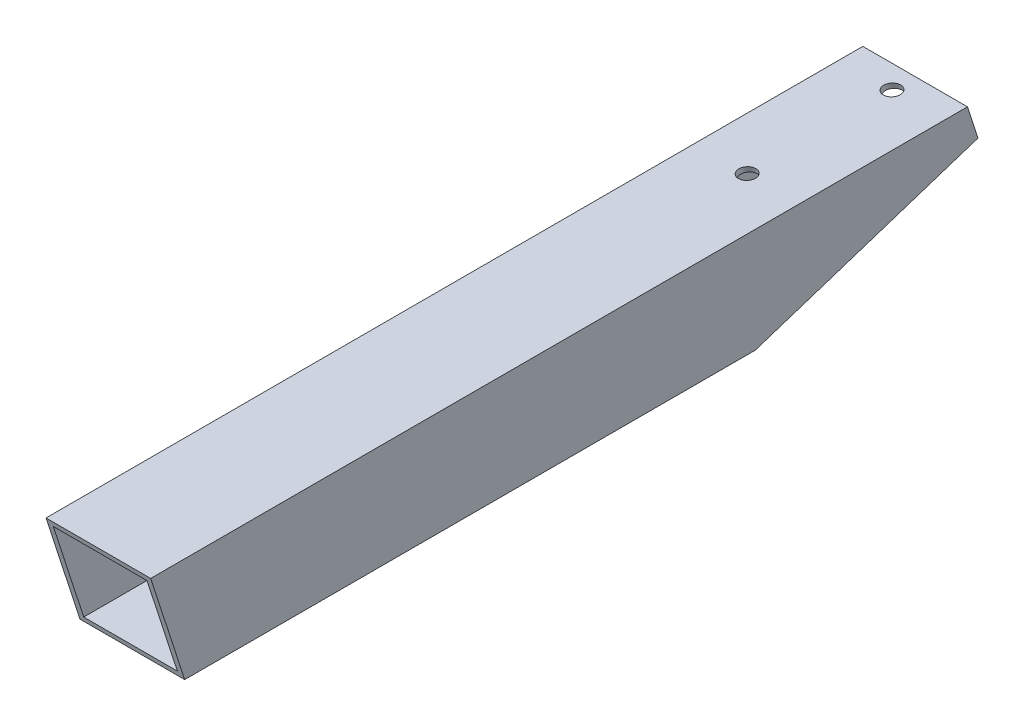
from build123d import *

# Parameters (mm, degrees)
ESBO_O1_W                = 19
ESBO_O1_H                = 19
RESSALTO_EXTRUS_O1_DEPTH = 260
CASCA2_T                 = -1
CORTE_EXTRUS_O1_DEPTH    = 20
CORTE_EXTRUS_O3_DEPTH    = 20
ESBO_O5_R                = 1.5
CORTE_EXTRUS_O4_DEPTH    = 52.987151397
ESBO_O7_W                = 19
ESBO_O7_H                = 19
CORTE_EXTRUS_O6_DEPTH    = 52.987151397


with BuildPart() as part:
    # Esboço1 → Ressalto-extrusão1 (new body)
    with BuildSketch(Plane.XY):
        Rectangle(ESBO_O1_W, ESBO_O1_H)
    extrude(amount=RESSALTO_EXTRUS_O1_DEPTH)

    # Casca2
    casca2_openings = [part.faces().sort_by_distance(p)[0] for p in [
        (0, 0, 260),
        (0, 0, 0),
    ]]
    offset(amount=CASCA2_T, openings=casca2_openings, kind=Kind.INTERSECTION)

    # Esboço2 → Corte-extrusão1 (cut, through all)
    with BuildSketch(Plane(origin=(9.5, 0, 0), x_dir=(0, 0, -1), z_dir=(1, 0, 0))):
        Polygon((0, 9.5), (-58.475987206, -9.5), (0, -9.5), align=None)
    extrude(amount=-CORTE_EXTRUS_O1_DEPTH, mode=Mode.SUBTRACT)

    # Esboço4 → Corte-extrusão3 (cut, through all)
    with BuildSketch(Plane(origin=(9.5, 0, 0), x_dir=(0, 0, -1), z_dir=(1, 0, 0))):
        Polygon((-168.550335734, 10.473717073), (-161.289503816, -11.872825786), (-264.812755879, -45.509569399), (-289.05777752, 22.149749677), (-184.516070462, 59.611196004), align=None)
    extrude(amount=-CORTE_EXTRUS_O3_DEPTH, mode=Mode.SUBTRACT)

    # Esboço5 → Corte-extrusão4 (cut, through all)
    with BuildSketch(Plane(origin=(0, 9.5, 0), x_dir=(1, 0, 0), z_dir=(0, 0.951056516, 0.309016994))):
        with Locations((0, -23)):
            Circle(ESBO_O5_R)
        with Locations((0, -48)):
            Circle(ESBO_O5_R)
    extrude(amount=CORTE_EXTRUS_O4_DEPTH, mode=Mode.SUBTRACT)

    # Esboço7 → Corte-extrusão6 (cut, through all)
    with BuildSketch(Plane(origin=(0, 8.592830723, 2.791979948), x_dir=(1, 0, 0), z_dir=(0, -0.951056516, -0.309016994))):
        with Locations((0, 6.564338553)):
            Rectangle(ESBO_O7_W, ESBO_O7_H)
    extrude(amount=-CORTE_EXTRUS_O6_DEPTH, mode=Mode.SUBTRACT)


solid = part.part
